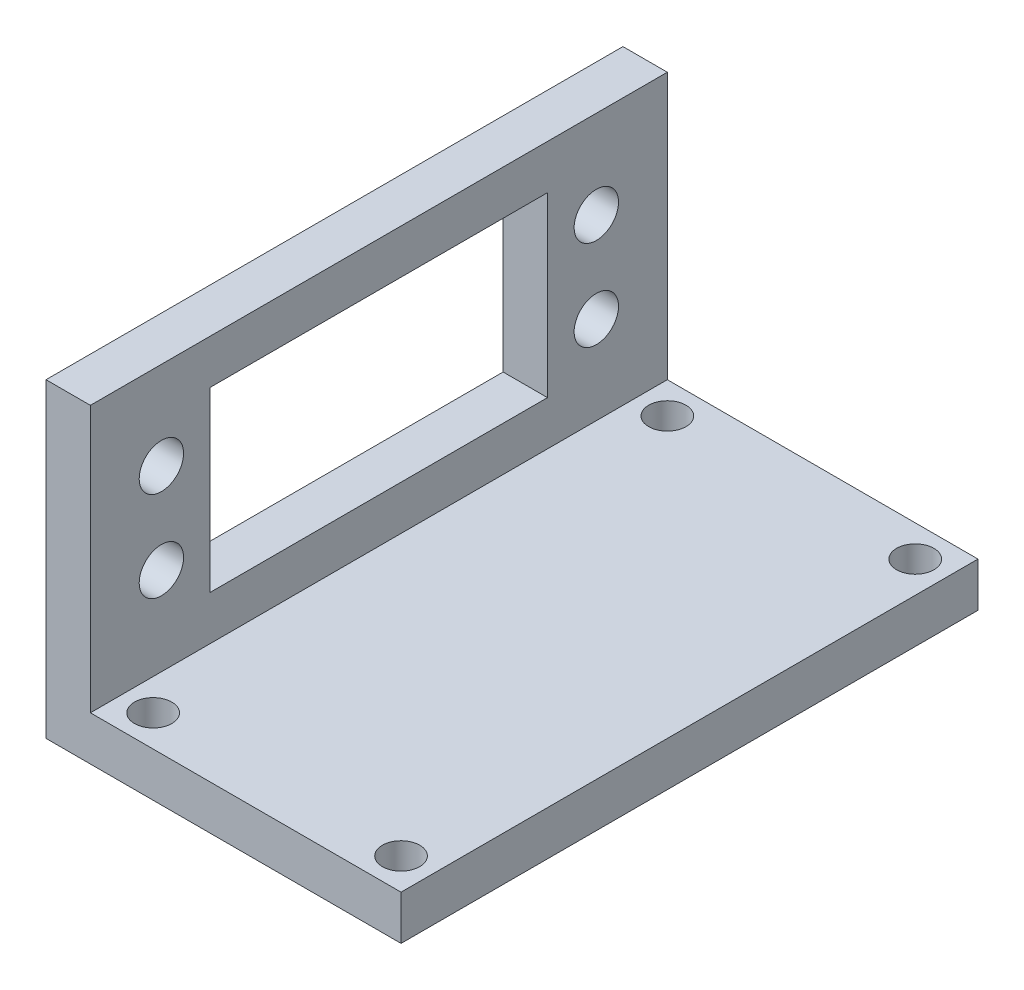
from build123d import *

# Parameters (mm, degrees)
BOSS_EXTRUDE1_DEPTH = 65
SKETCH2_R           = 2.5
CUT_EXTRUDE1_DEPTH  = 10
SKETCH3_W           = 38
SKETCH3_H           = 20
CUT_EXTRUDE2_DEPTH  = 10
SKETCH6_R           = 2.1
CUT_EXTRUDE5_DEPTH  = 6


with BuildPart() as part:
    # Sketch1 → Boss-Extrude1 (new body)
    with BuildSketch(Plane.XY):
        Polygon((0, 0), (0, 35), (5, 35), (5, 5), (40, 5), (40, 0), align=None)
    extrude(amount=BOSS_EXTRUDE1_DEPTH)

    # Sketch2 → Cut-Extrude1 (cut)
    with BuildSketch(Plane(origin=(5, 0, 0), x_dir=(0, 0, -1), z_dir=(1, 0, 0))):
        with Locations((-8, 25.08)):
            Circle(SKETCH2_R)
        with Locations((-8, 14.92)):
            Circle(SKETCH2_R)
        with Locations((-57, 25.08)):
            Circle(SKETCH2_R)
        with Locations((-57, 14.92)):
            Circle(SKETCH2_R)
    extrude(amount=-CUT_EXTRUDE1_DEPTH, mode=Mode.SUBTRACT)

    # Sketch3 → Cut-Extrude2 (cut)
    with BuildSketch(Plane.ZY):
        with Locations((32.5, 20)):
            Rectangle(SKETCH3_W, SKETCH3_H)
    extrude(amount=-CUT_EXTRUDE2_DEPTH, mode=Mode.SUBTRACT)

    # Sketch6 → Cut-Extrude5 (cut, through all)
    with BuildSketch(Plane(origin=(0, 5, 0), x_dir=(1, 0, 0), z_dir=(0, 1, 0))):
        with Locations((36.464466094, -3.535533906)):
            Circle(SKETCH6_R)
        with Locations((8.535533906, -3.535533906)):
            Circle(SKETCH6_R)
        with Locations((36.464466094, -61.464466094)):
            Circle(SKETCH6_R)
        with Locations((8.535533906, -61.464466094)):
            Circle(SKETCH6_R)
    extrude(amount=-CUT_EXTRUDE5_DEPTH, mode=Mode.SUBTRACT)


solid = part.part
